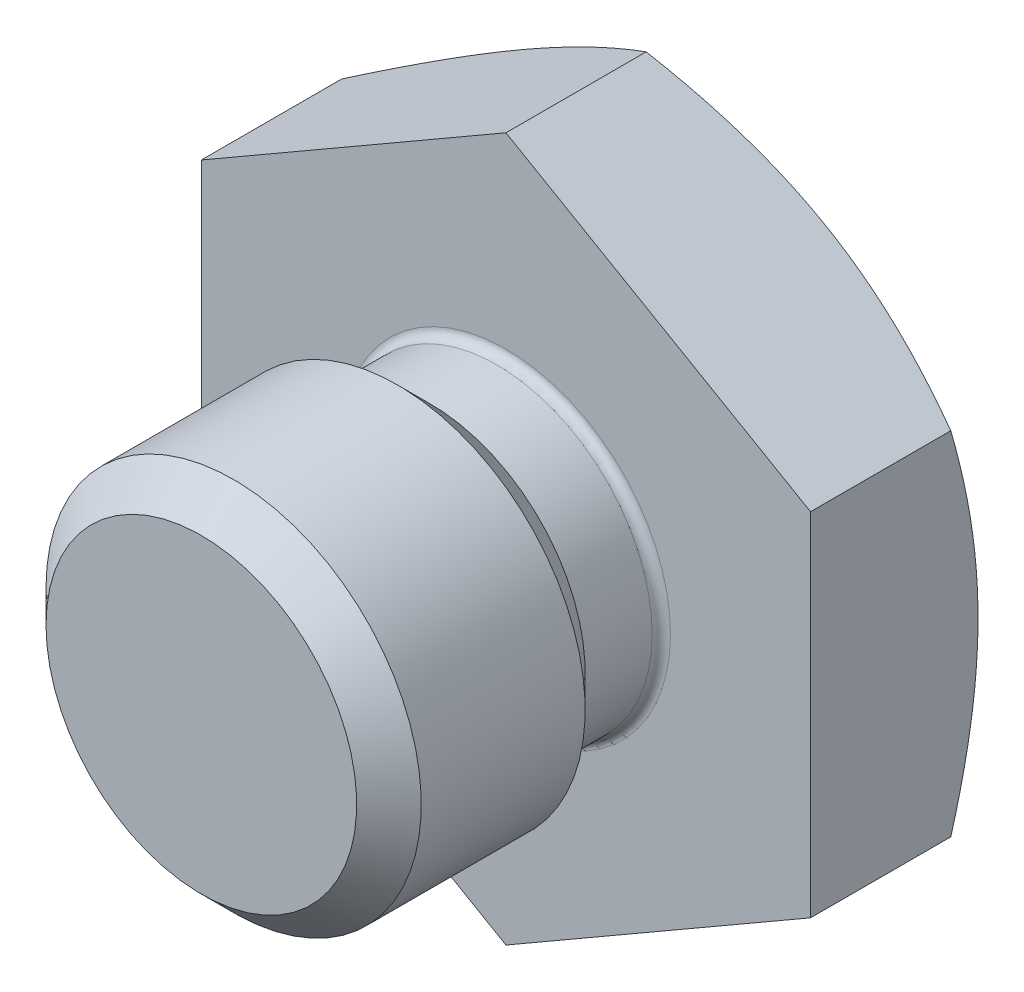
from build123d import *

# Parameters (mm, degrees)
SKETCH2_OUTSIDE_W  = 66.612
SKETCH2_OUTSIDE_H  = 66.612
CUT_EXTRUDE1_DEPTH = 15.2748
FILLET1_R          = 0.381


with BuildPart() as part:
    # Sketch1 → Revolve1 (revolve)
    with BuildSketch(Plane(origin=(0, 0, 0), x_dir=(0, 0, -1), z_dir=(1, 0, 0)), mode=Mode.PRIVATE) as revolve1_sk:
        with BuildLine():
            Line((0, 24.792737963), (0, 6.477))
            Line((0, 6.477), (-3.175, 6.477))
            Line((-3.175, 6.477), (-4.5212, 7.8232))
            Line((-4.5212, 7.8232), (-11.3538, 7.8232))
            Line((-11.3538, 7.8232), (-12.7, 6.477))
            Line((-12.7, 6.477), (-12.7, 0))
            Line((-12.7, 0), (14.2748, 0))
            ThreePointArc((14.2748, 0), (14.26614516, 0.065740037), (14.240770453, 0.127))
            Line((14.240770453, 0.127), (0, 24.792737963))
        make_face()
    revolve(revolve1_sk.sketch.rotate(Axis((0, 0, 0), (0, 0, 1)), 90), axis=Axis((0, 0, 0), (0, 0, 1)))  # turned: the seam where the file's is

    # Sketch2 outside → Cut-Extrude1 (cut, through all)
    with BuildSketch(Plane.XY):
        Rectangle(SKETCH2_OUTSIDE_W, SKETCH2_OUTSIDE_H)
        Polygon((0, 14.664696837), (-12.7, 7.332348419), (-12.7, -7.332348419), (0, -14.664696837), (12.7, -7.332348419), (12.7, 7.332348419), align=None, mode=Mode.SUBTRACT)
    extrude(amount=-CUT_EXTRUDE1_DEPTH, mode=Mode.SUBTRACT)

    # Fillet1
    fillet1_edges = [part.edges().sort_by_distance(p)[0] for p in [
        (6.477, 0, 0),
    ]]
    fillet(fillet1_edges, radius=FILLET1_R)


solid = part.part
